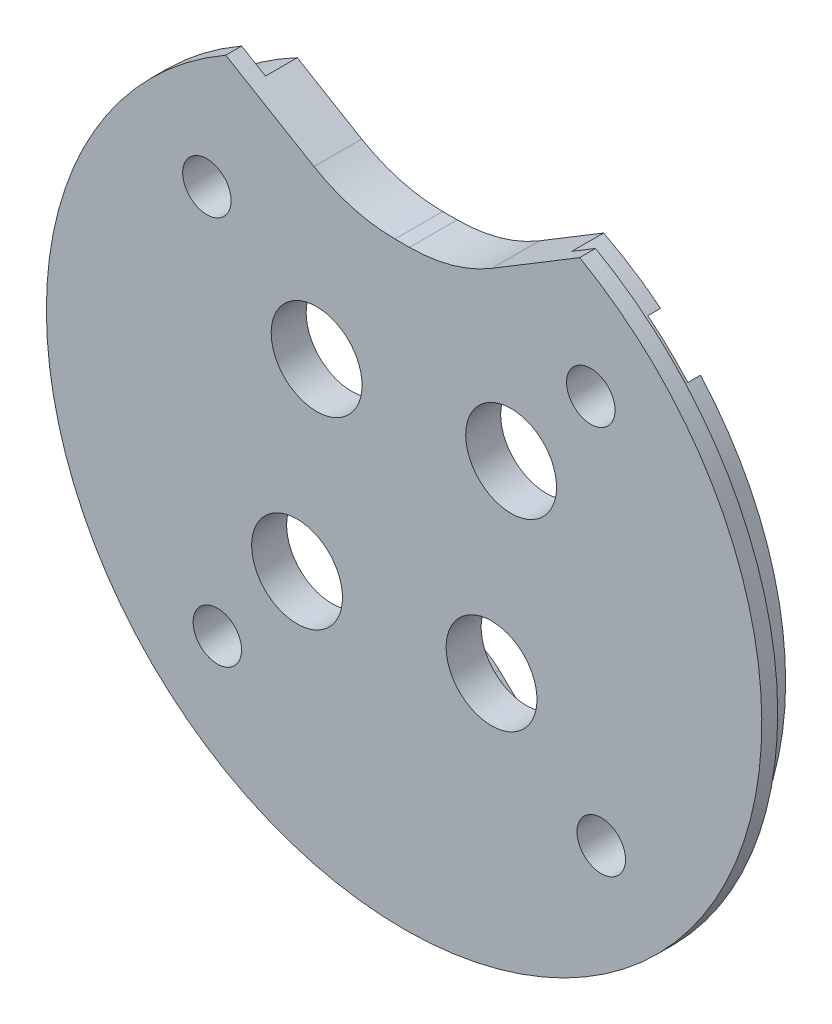
from build123d import *

# Parameters (mm, degrees)
SKETCH1_R           = 21
BOSS_EXTRUDE1_DEPTH = 2
SKETCH2_R           = 22.5
BOSS_EXTRUDE2_DEPTH = 1
CUT_EXTRUDE1_DEPTH  = 0.8
CUT_EXTRUDE2_REACH  = 5
SKETCH4_R           = 1.524
SKETCH4_R_2         = 2.8575


with BuildPart() as part:
    # Sketch1 → Boss-Extrude1 (new body)
    with BuildSketch(Plane.XY):
        Circle(SKETCH1_R)
    extrude(amount=BOSS_EXTRUDE1_DEPTH)

    # Sketch2 → Boss-Extrude2 (add)
    with BuildSketch(Plane.XY.offset(2)):
        Circle(SKETCH2_R)
    extrude(amount=BOSS_EXTRUDE2_DEPTH)

    # Sketch3 → Cut-Extrude1 (cut)
    with BuildSketch(Plane(origin=(0, 0, 0), x_dir=(-1, 0, 0), z_dir=(0, 0, -1))):
        with BuildLine():
            Line((15.536569667, 14.527364659), (15.351441673, 14.722858401))
            ThreePointArc((15.351441673, 14.722858401), (12.623062926, 15.941035549), (9.832426491, 14.873161756))
            Line((9.832426491, 14.873161756), (2.990145498, 8.393681964))
            ThreePointArc((2.990145498, 8.393681964), (0.199509062, 7.325808172), (-2.528869685, 8.543985319))
            Line((-2.528869685, 8.543985319), (-9.008349476, 15.386266312))
            ThreePointArc((-9.008349476, 15.386266312), (-11.736728224, 16.604443459), (-14.527364659, 15.536569667))
            Line((-14.527364659, 15.536569667), (-14.722858401, 15.351441673))
            ThreePointArc((-14.722858401, 15.351441673), (-15.941035549, 12.623062926), (-14.873161756, 9.832426491))
            Line((-14.873161756, 9.832426491), (-8.393681964, 2.990145498))
            ThreePointArc((-8.393681964, 2.990145498), (-7.325808172, 0.199509062), (-8.543985319, -2.528869685))
            Line((-8.543985319, -2.528869685), (-15.386266312, -9.008349476))
            ThreePointArc((-15.386266312, -9.008349476), (-16.604443459, -11.736728224), (-15.536569667, -14.527364659))
            Line((-15.536569667, -14.527364659), (-15.351441673, -14.722858401))
            ThreePointArc((-15.351441673, -14.722858401), (-12.623062926, -15.941035549), (-9.832426491, -14.873161756))
            Line((-9.832426491, -14.873161756), (-2.990145498, -8.393681964))
            ThreePointArc((-2.990145498, -8.393681964), (-0.199509062, -7.325808172), (2.528869685, -8.543985319))
            Line((2.528869685, -8.543985319), (9.008349476, -15.386266312))
            ThreePointArc((9.008349476, -15.386266312), (11.736728224, -16.604443459), (14.527364659, -15.536569667))
            Line((14.527364659, -15.536569667), (14.722858401, -15.351441673))
            ThreePointArc((14.722858401, -15.351441673), (15.941035549, -12.623062926), (14.873161756, -9.832426491))
            Line((14.873161756, -9.832426491), (8.393681964, -2.990145498))
            ThreePointArc((8.393681964, -2.990145498), (7.325808172, -0.199509062), (8.543985319, 2.528869685))
            Line((8.543985319, 2.528869685), (15.386266312, 9.008349476))
            ThreePointArc((15.386266312, 9.008349476), (16.604443459, 11.736728224), (15.536569667, 14.527364659))
        make_face()
    extrude(amount=-CUT_EXTRUDE1_DEPTH, mode=Mode.SUBTRACT)

    # Sketch4 → Cut-Extrude2 (cut, up to next)
    with BuildSketch(Plane(origin=(0, 0, 0), x_dir=(-1, 0, 0), z_dir=(0, 0, -1)), mode=Mode.PRIVATE) as cut_extrude2_sk1:
        with Locations((12.402786975, 11.745148679)):
            Circle(SKETCH4_R)
    cut_extrude2_tool1 = extrude(cut_extrude2_sk1.sketch, amount=-CUT_EXTRUDE2_REACH, mode=Mode.PRIVATE) & part.part
    add(cut_extrude2_tool1.solids().sort_by_distance((-12.402787, 11.745149, 0))[0], mode=Mode.SUBTRACT)
    # Sketch4 → Cut-Extrude2 (cut, up to next)
    with BuildSketch(Plane(origin=(0, 0, 0), x_dir=(-1, 0, 0), z_dir=(0, 0, -1)), mode=Mode.PRIVATE) as cut_extrude2_sk2:
        with Locations((11.745148679, -12.402786975)):
            Circle(SKETCH4_R)
    cut_extrude2_tool2 = extrude(cut_extrude2_sk2.sketch, amount=-CUT_EXTRUDE2_REACH, mode=Mode.PRIVATE) & part.part
    add(cut_extrude2_tool2.solids().sort_by_distance((-11.745149, -12.402787, 0))[0], mode=Mode.SUBTRACT)
    # Sketch4 → Cut-Extrude2 (cut, up to next)
    with BuildSketch(Plane(origin=(0, 0, 0), x_dir=(-1, 0, 0), z_dir=(0, 0, -1)), mode=Mode.PRIVATE) as cut_extrude2_sk3:
        with Locations((-12.402786975, -11.745148679)):
            Circle(SKETCH4_R)
    cut_extrude2_tool3 = extrude(cut_extrude2_sk3.sketch, amount=-CUT_EXTRUDE2_REACH, mode=Mode.PRIVATE) & part.part
    add(cut_extrude2_tool3.solids().sort_by_distance((12.402787, -11.745149, 0))[0], mode=Mode.SUBTRACT)
    # Sketch4 → Cut-Extrude2 (cut, up to next)
    with BuildSketch(Plane(origin=(0, 0, 0), x_dir=(-1, 0, 0), z_dir=(0, 0, -1)), mode=Mode.PRIVATE) as cut_extrude2_sk4:
        with Locations((-11.745148679, 12.402786975)):
            Circle(SKETCH4_R)
    cut_extrude2_tool4 = extrude(cut_extrude2_sk4.sketch, amount=-CUT_EXTRUDE2_REACH, mode=Mode.PRIVATE) & part.part
    add(cut_extrude2_tool4.solids().sort_by_distance((11.745149, 12.402787, 0))[0], mode=Mode.SUBTRACT)
    # Sketch4 → Cut-Extrude2 (cut, up to next)
    with BuildSketch(Plane(origin=(0, 0, 0), x_dir=(-1, 0, 0), z_dir=(0, 0, -1)), mode=Mode.PRIVATE) as cut_extrude2_sk5:
        with Locations((6.731624158, -6.374690361)):
            Circle(SKETCH4_R_2)
    cut_extrude2_tool5 = extrude(cut_extrude2_sk5.sketch, amount=-CUT_EXTRUDE2_REACH, mode=Mode.PRIVATE) & part.part
    add(cut_extrude2_tool5.solids().sort_by_distance((-6.731624, -6.37469, 0))[0], mode=Mode.SUBTRACT)
    # Sketch4 → Cut-Extrude2 (cut, up to next)
    with BuildSketch(Plane(origin=(0, 0, 0), x_dir=(-1, 0, 0), z_dir=(0, 0, -1)), mode=Mode.PRIVATE) as cut_extrude2_sk6:
        with Locations((5.501445106, 5.809483862)):
            Circle(SKETCH4_R_2)
    cut_extrude2_tool6 = extrude(cut_extrude2_sk6.sketch, amount=-CUT_EXTRUDE2_REACH, mode=Mode.PRIVATE) & part.part
    add(cut_extrude2_tool6.solids().sort_by_distance((-5.501445, 5.809484, 0))[0], mode=Mode.SUBTRACT)
    # Sketch4 → Cut-Extrude2 (cut, up to next)
    with BuildSketch(Plane(origin=(0, 0, 0), x_dir=(-1, 0, 0), z_dir=(0, 0, -1)), mode=Mode.PRIVATE) as cut_extrude2_sk7:
        with Locations((-5.501445106, -5.809483862)):
            Circle(SKETCH4_R_2)
    cut_extrude2_tool7 = extrude(cut_extrude2_sk7.sketch, amount=-CUT_EXTRUDE2_REACH, mode=Mode.PRIVATE) & part.part
    add(cut_extrude2_tool7.solids().sort_by_distance((5.501445, -5.809484, 0))[0], mode=Mode.SUBTRACT)
    # Sketch4 → Cut-Extrude2 (cut, up to next)
    with BuildSketch(Plane(origin=(0, 0, 0), x_dir=(-1, 0, 0), z_dir=(0, 0, -1)), mode=Mode.PRIVATE) as cut_extrude2_sk8:
        with Locations((-6.731624158, 6.374690361)):
            Circle(SKETCH4_R_2)
    cut_extrude2_tool8 = extrude(cut_extrude2_sk8.sketch, amount=-CUT_EXTRUDE2_REACH, mode=Mode.PRIVATE) & part.part
    add(cut_extrude2_tool8.solids().sort_by_distance((6.731624, 6.37469, 0))[0], mode=Mode.SUBTRACT)
    # Sketch4 → Cut-Extrude2 (cut, up to next)
    with BuildSketch(Plane(origin=(0, 0, 0), x_dir=(-1, 0, 0), z_dir=(0, 0, -1)), mode=Mode.PRIVATE) as cut_extrude2_sk9:
        with BuildLine():
            Line((-11.040615308, 19.604969105), (-5.51854435, 16.261312284))
            ThreePointArc((-5.51854435, 16.261312284), (-3.027783619, 15.183648482), (-0.338986288, 14.815386067))
            Line((-0.338986288, 14.815386067), (0.567529778, 14.815386067))
            ThreePointArc((0.567529778, 14.815386067), (3.210473763, 15.170965551), (5.665462417, 16.212416649))
            Line((5.665462417, 16.212416649), (11.219097888, 19.503380286))
            ThreePointArc((11.219097888, 19.503380286), (0.10268437, 22.499765686), (-11.040615308, 19.604969105))
        make_face()
    cut_extrude2_tool9 = extrude(cut_extrude2_sk9.sketch, amount=-CUT_EXTRUDE2_REACH, mode=Mode.PRIVATE) & part.part
    add(cut_extrude2_tool9.solids().sort_by_distance((-0.08522, 18.896567, 0))[0], mode=Mode.SUBTRACT)


solid = part.part
